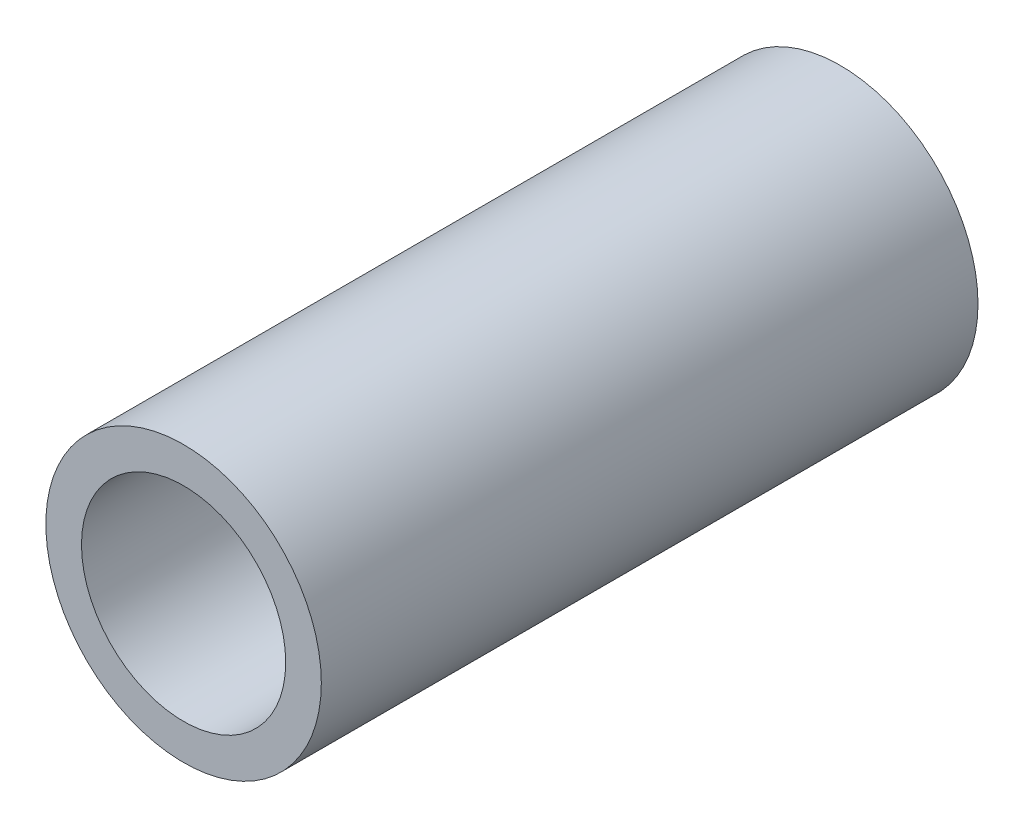
from build123d import *

# Parameters (mm, degrees)
SKETCH1_R           = 10.6553
SKETCH1_R_2         = 7.8994
BOSS_EXTRUDE1_DEPTH = 50.8


with BuildPart() as part:
    # Sketch1 → Boss-Extrude1 (new body)
    with BuildSketch(Plane.XY):
        Circle(SKETCH1_R)
        Circle(SKETCH1_R_2, mode=Mode.SUBTRACT)
    extrude(amount=BOSS_EXTRUDE1_DEPTH)


solid = part.part
